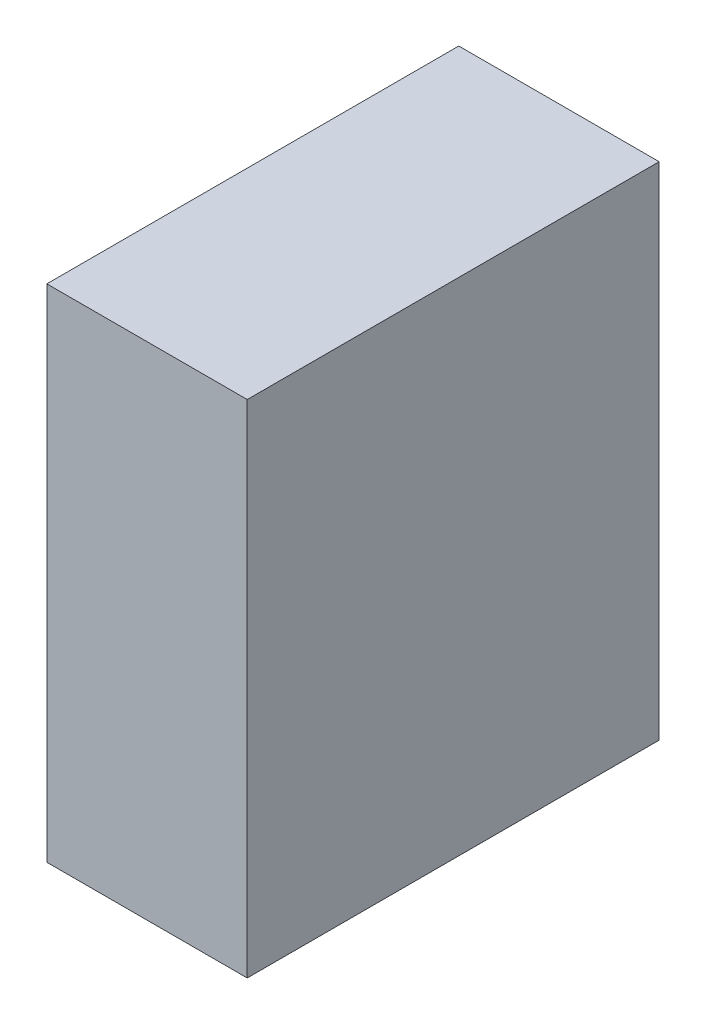
from build123d import *

# Parameters (mm, degrees)
SKETCH2_W           = 180
SKETCH2_H           = 370
BOSS_EXTRUDE1_DEPTH = 450


with BuildPart() as part:
    # Sketch2 → Boss-Extrude1 (new body)
    with BuildSketch(Plane(origin=(0, 0, 0), x_dir=(1, 0, 0), z_dir=(0, 1, 0))):
        Rectangle(SKETCH2_W, SKETCH2_H)
    extrude(amount=BOSS_EXTRUDE1_DEPTH)


solid = part.part
